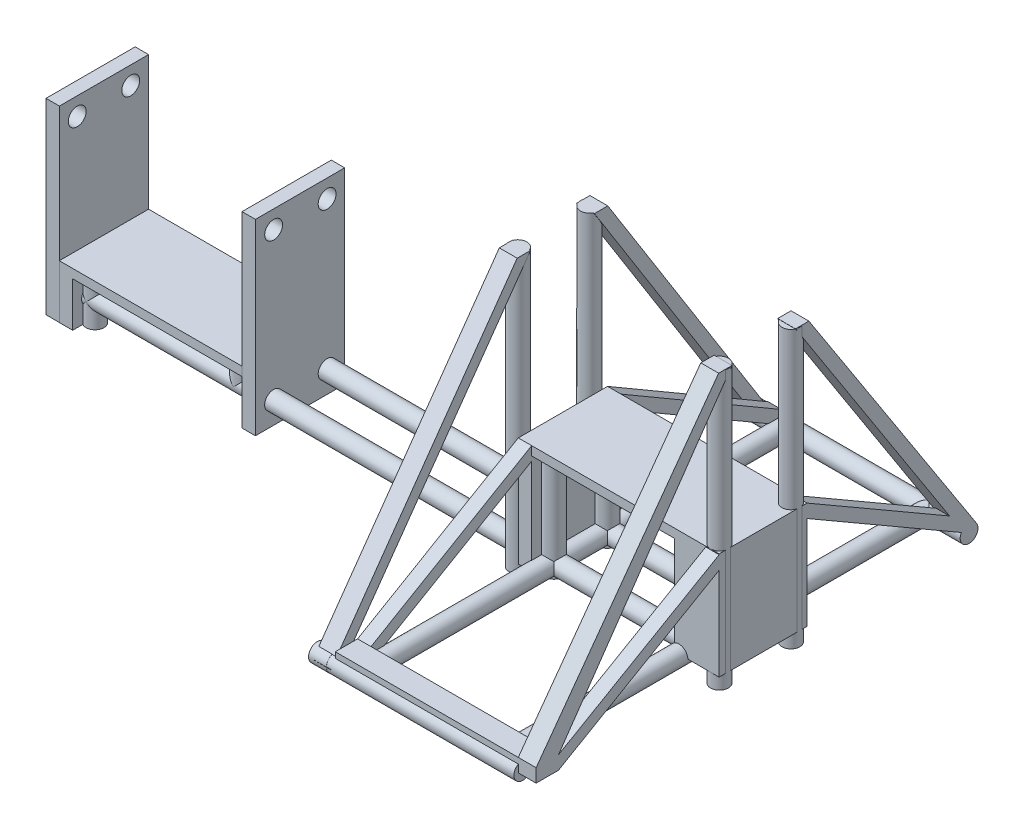
from build123d import *

# Parameters (mm, degrees)
SKETCH1_W                 = 41
SKETCH1_H                 = 20
BOSS_EXTRUDE2_DEPTH       = 2
SKETCH2_R                 = 2
BOSS_EXTRUDE5_DEPTH       = 10
SKETCH4_R                 = 2
BOSS_EXTRUDE6_DEPTH       = 5
BOSS_EXTRUDE7_DEPTH       = 100
BOSS_EXTRUDE7_DEPTH_BACK  = 38
SKETCH5_R                 = 2
BOSS_EXTRUDE8_DEPTH       = 15
BOSS_EXTRUDE8_DEPTH_BACK  = 9
SKETCH6_R                 = 2
SKETCH7_W                 = 41
SKETCH7_H                 = 20
BOSS_EXTRUDE9_DEPTH       = 2
BOSS_EXTRUDE10_DEPTH      = 40
BOSS_EXTRUDE10_DEPTH_BACK = 56
SKETCH8_R                 = 2
SKETCH9_R                 = 1.979655777
SKETCH9_R_2               = 2
BOSS_EXTRUDE11_DEPTH      = 42
SKETCH12_W                = 20
SKETCH12_H                = 24.471950771
BOSS_EXTRUDE15_DEPTH      = 3
BOSS_EXTRUDE17_DEPTH      = 35
BOSS_EXTRUDE17_DEPTH_BACK = 27
SKETCH14_R                = 2
BOSS_EXTRUDE18_DEPTH      = 4
BOSS_EXTRUDE18_DEPTH_BACK = 6
SKETCH15_W                = 19.713021989
SKETCH15_H                = 23.922697732
SKETCH17_W                = 20
SKETCH17_H                = 12
BOSS_EXTRUDE20_DEPTH      = 3
SKETCH19_W                = 20
SKETCH19_H                = 42
BOSS_EXTRUDE23_DEPTH      = 3
SKETCH21_W                = 19.981889494
SKETCH21_H                = 42
BOSS_EXTRUDE24_DEPTH      = 3
SKETCH22_R                = 2
CUT_EXTRUDE1_DEPTH        = 52
BOSS_EXTRUDE25_DEPTH      = 3
BOSS_EXTRUDE26_DEPTH      = 3
SKETCH25_R                = 2
BOSS_EXTRUDE27_DEPTH      = 4
SKETCH26_W                = 45
SKETCH26_H                = 3
BOSS_EXTRUDE28_DEPTH      = 5
BOSS_EXTRUDE29_DEPTH      = 4
BOSS_EXTRUDE30_DEPTH      = 4
SKETCH31_R                = 2
BOSS_EXTRUDE31_DEPTH      = 4
SKETCH32_R                = 2
BOSS_EXTRUDE32_DEPTH      = 4


with BuildPart() as part:
    # Sketch1 → Boss-Extrude2 (new body)
    with BuildSketch(Plane(origin=(0, 0, 0), x_dir=(1, 0, 0), z_dir=(0, 1, 0))):
        with Locations((-5.183853206, 62.330850907)):
            Rectangle(SKETCH1_W, SKETCH1_H)
    extrude(amount=BOSS_EXTRUDE2_DEPTH)

    # Sketch2 → Boss-Extrude5 (add)
    with BuildSketch(Plane(origin=(0, 0, 0), x_dir=(-1, 0, 0), z_dir=(0, -1, 0))):
        with Locations((21.683853206, 56.330850907)):
            Circle(SKETCH2_R)
        with Locations((21.683853206, 68.330850907)):
            Circle(SKETCH2_R)
    extrude(amount=BOSS_EXTRUDE5_DEPTH)

    # Sketch4 → Boss-Extrude6 (add)
    with BuildSketch(Plane(origin=(0, 0, 0), x_dir=(-1, 0, 0), z_dir=(0, -1, 0))):
        with Locations((-11.316146794, 56.330850907)):
            Circle(SKETCH4_R)
        with Locations((-11.316146794, 68.330850907)):
            Circle(SKETCH4_R)
    extrude(amount=BOSS_EXTRUDE6_DEPTH)

    # Sketch5 → Boss-Extrude7 (add, two sides: drawn at the far end of the back side and taken through both)
    with BuildSketch(Plane(origin=(15.316146794, 0, 0), x_dir=(0, 0, -1), z_dir=(1, 0, 0)).offset(-BOSS_EXTRUDE7_DEPTH_BACK)):
        with Locations((56.330850907, -4.990061884)):
            Circle(SKETCH5_R)
        with Locations((68.330850907, -4.990061884)):
            Circle(SKETCH5_R)
    extrude(amount=BOSS_EXTRUDE7_DEPTH + BOSS_EXTRUDE7_DEPTH_BACK)

    # Sketch6 → Boss-Extrude8 (add, two sides: drawn at the far end of the back side and taken through both)
    with BuildSketch(Plane(origin=(0, 2, 0), x_dir=(1, 0, 0), z_dir=(0, 1, 0)).offset(-BOSS_EXTRUDE8_DEPTH_BACK)):
        with Locations((113.110714063, 56.330850907)):
            Circle(SKETCH6_R)
        with Locations((113.110714063, 68.330850907)):
            Circle(SKETCH6_R)
        with Locations((81.110714063, 68.330850907)):
            Circle(SKETCH6_R)
        with Locations((81.110714063, 56.330850907)):
            Circle(SKETCH6_R)
    extrude(amount=BOSS_EXTRUDE8_DEPTH + BOSS_EXTRUDE8_DEPTH_BACK)

    # Sketch7 → Boss-Extrude9 (add)
    with BuildSketch(Plane(origin=(0, 17, 0), x_dir=(1, 0, 0), z_dir=(0, 1, 0))):
        with Locations((97.610714063, 62.366575909)):
            Rectangle(SKETCH7_W, SKETCH7_H)
    extrude(amount=BOSS_EXTRUDE9_DEPTH)

    # Sketch8 → Boss-Extrude10 (add, two sides: drawn at the far end of the back side and taken through both)
    with BuildSketch(Plane.XY.offset(-52.366575909).offset(-BOSS_EXTRUDE10_DEPTH_BACK)):
        with Locations((81.110714063, -4.990061884)):
            Circle(SKETCH8_R)
        with Locations((113.110714063, -4.990061884)):
            Circle(SKETCH8_R)
    extrude(amount=BOSS_EXTRUDE10_DEPTH + BOSS_EXTRUDE10_DEPTH_BACK)

    # Sketch9 → Boss-Extrude11 (add)
    with BuildSketch(Plane(origin=(118.110714063, 0, 0), x_dir=(0, 0, -1), z_dir=(1, 0, 0))):
        with Locations((12.366575909, -4.990061884)):
            Circle(SKETCH9_R)
        with Locations((108.366575909, -4.990061884)):
            Circle(SKETCH9_R_2)
    extrude(amount=-BOSS_EXTRUDE11_DEPTH)

    # Sketch12 → Boss-Extrude15 (add)
    with BuildSketch(Plane.ZY.offset(-77.110714063)):
        with Locations((-62.366575909, 6.764024615)):
            Rectangle(SKETCH12_W, SKETCH12_H)
    extrude(amount=-BOSS_EXTRUDE15_DEPTH)

    # Sketch14 → Boss-Extrude17 (add, two sides: drawn at the far end of the back side and taken through both)
    with BuildSketch(Plane(origin=(0, 19, 0), x_dir=(1, 0, 0), z_dir=(0, 1, 0)).offset(-BOSS_EXTRUDE17_DEPTH_BACK)):
        with Locations((75.036356437, 70.366575909)):
            Circle(SKETCH14_R)
        with Locations((75.036356437, 54.366575909)):
            Circle(SKETCH14_R)
        with Locations((120.18507169, 70.366575909)):
            Circle(SKETCH14_R)
        with Locations((120.18507169, 54.366575909)):
            Circle(SKETCH14_R)
    extrude(amount=BOSS_EXTRUDE17_DEPTH + BOSS_EXTRUDE17_DEPTH_BACK)


with BuildPart() as boss_extrude17_piece_1:
    # of the separate pieces the step leaves, piece 1, a body of its own (boss_extrude17_pieces)
    add(part.part.solids().sort_by_distance((118.110714063, 19, -52.366575909))[0])



with BuildPart() as boss_extrude17_piece_2:
    # of the separate pieces the step leaves, piece 2, a body of its own (boss_extrude17_pieces)
    add(part.part.solids().sort_by_distance((122.18507169, 19, -70.366575909))[0])


with BuildPart() as boss_extrude17_piece_3:
    # of the separate pieces the step leaves, piece 3, a body of its own (boss_extrude17_pieces)
    add(part.part.solids().sort_by_distance((122.18507169, 19, -54.366575909))[0])


with BuildPart() as boss_extrude17_piece_1_1:
    add(boss_extrude17_piece_1.part)

    add(boss_extrude17_piece_2.part)  # Boss-Extrude18 merges Boss-Extrude17 piece 2

    add(boss_extrude17_piece_3.part)  # Boss-Extrude18 merges Boss-Extrude17 piece 3
    # Sketch15 → Boss-Extrude18 (add, two sides: drawn at the far end of the back side and taken through both)
    with BuildSketch(Plane(origin=(118.110714063, 0, 0), x_dir=(0, 0, -1), z_dir=(1, 0, 0)).offset(-BOSS_EXTRUDE18_DEPTH_BACK)):
        with Locations((62.223086904, 7.038651134)):
            Rectangle(SKETCH15_W, SKETCH15_H)
    extrude(amount=BOSS_EXTRUDE18_DEPTH + BOSS_EXTRUDE18_DEPTH_BACK)

    # Sketch17 → Boss-Extrude20 (add)
    with BuildSketch(Plane.ZY.offset(25.683853206)):
        with Locations((-62.330850907, -4)):
            Rectangle(SKETCH17_W, SKETCH17_H)
    extrude(amount=-BOSS_EXTRUDE20_DEPTH)

    # Sketch19 → Boss-Extrude23 (add)
    with BuildSketch(Plane(origin=(15.316146794, 0, 0), x_dir=(0, 0, -1), z_dir=(1, 0, 0))):
        with Locations((62.269226743, 11.056371967)):
            Rectangle(SKETCH19_W, SKETCH19_H)
    extrude(amount=BOSS_EXTRUDE23_DEPTH)

    # Sketch21 → Boss-Extrude24 (add)
    with BuildSketch(Plane.ZY.offset(25.683853206)):
        with Locations((-62.33990616, 11)):
            Rectangle(SKETCH21_W, SKETCH21_H)
    extrude(amount=BOSS_EXTRUDE24_DEPTH)

    # Sketch22 → Cut-Extrude1 (cut)
    with BuildSketch(Plane.ZY.offset(28.683853206)):
        with Locations((-68.330850907, 28)):
            Circle(SKETCH22_R)
        with Locations((-56.348961413, 28)):
            Circle(SKETCH22_R)
    extrude(amount=-CUT_EXTRUDE1_DEPTH, mode=Mode.SUBTRACT)

    # Sketch23 → Boss-Extrude25 (add)
    with BuildSketch(Plane.ZY.offset(-77.110714063)):
        Polygon((-72.366575909, 16), (-72.366575909, 19), (-108.366575909, -1.990061884), (-108.366575909, -4.990061884), align=None)
        Polygon((-52.366575909, 19), (-52.366575909, 16), (-16.366575909, -4.990061884), (-16.366575909, -1.990061884), align=None)
    extrude(amount=-BOSS_EXTRUDE25_DEPTH)

    # Sketch24 → Boss-Extrude26 (add)
    with BuildSketch(Plane(origin=(122.110714063, 0, 0), x_dir=(0, 0, -1), z_dir=(1, 0, 0))):
        Polygon((108.366575909, -1.990061884), (72.079597898, 19), (72.079597898, 16), (108.366575909, -4.990061884), align=None)
        Polygon((16.366575909, -4.990061884), (52.653553921, 16), (52.653553921, 19), (16.366575909, -1.990061884), align=None)
    extrude(amount=-BOSS_EXTRUDE26_DEPTH)

    # Sketch25 → Boss-Extrude27 (add)
    with BuildSketch(Plane(origin=(118.110714063, 0, 0), x_dir=(0, 0, -1), z_dir=(1, 0, 0))):
        with Locations((108.366575909, -4.990061884)):
            Circle(SKETCH25_R)
    extrude(amount=BOSS_EXTRUDE27_DEPTH)

    # Sketch26 → Boss-Extrude28 (add)
    with BuildSketch(Plane.XY.offset(-16.366575909)):
        with Locations((99.610714063, -3.490061884)):
            Rectangle(SKETCH26_W, SKETCH26_H)
    extrude(amount=BOSS_EXTRUDE28_DEPTH)

    # Sketch28 → Boss-Extrude29 (add)
    with BuildSketch(Plane(origin=(122.110714063, 0, 0), x_dir=(0, 0, -1), z_dir=(1, 0, 0))):
        Polygon((52.258506712, 54.11255065), (11.366575909, -1.990061884), (16.366575909, -1.990061884), (55.258506712, 54.11255065), align=None)
        Polygon((69.474645107, 54.11255065), (107.071254677, -4.240788334), (110.053605228, -3.915849578), (72.474645107, 54.11255065), align=None)
    extrude(amount=-BOSS_EXTRUDE29_DEPTH)

    # Sketch30 → Boss-Extrude30 (add)
    with BuildSketch(Plane.ZY.offset(-77.110714063)):
        Polygon((-109.806672673, -5.425606455), (-106.806672673, -5.425606455), (-69.419981691, 54), (-72.419981691, 54), align=None)
        Polygon((-13.351304607, -4.990061884), (-55.118471796, 54), (-52.118471796, 54), (-10.351304607, -4.990061884), align=None)
    extrude(amount=BOSS_EXTRUDE30_DEPTH)

    # Sketch31 → Boss-Extrude31 (add)
    with BuildSketch(Plane.ZY.offset(-76.110714063)):
        with Locations((-108.366575909, -4.990061884)):
            Circle(SKETCH31_R)
    extrude(amount=BOSS_EXTRUDE31_DEPTH)

    # Sketch32 → Boss-Extrude32 (add)
    with BuildSketch(Plane.ZY.offset(-76.110714063)):
        with Locations((-12.366575909, -4.990061884)):
            Circle(SKETCH32_R)
    extrude(amount=BOSS_EXTRUDE32_DEPTH)


solid = boss_extrude17_piece_1_1.part
